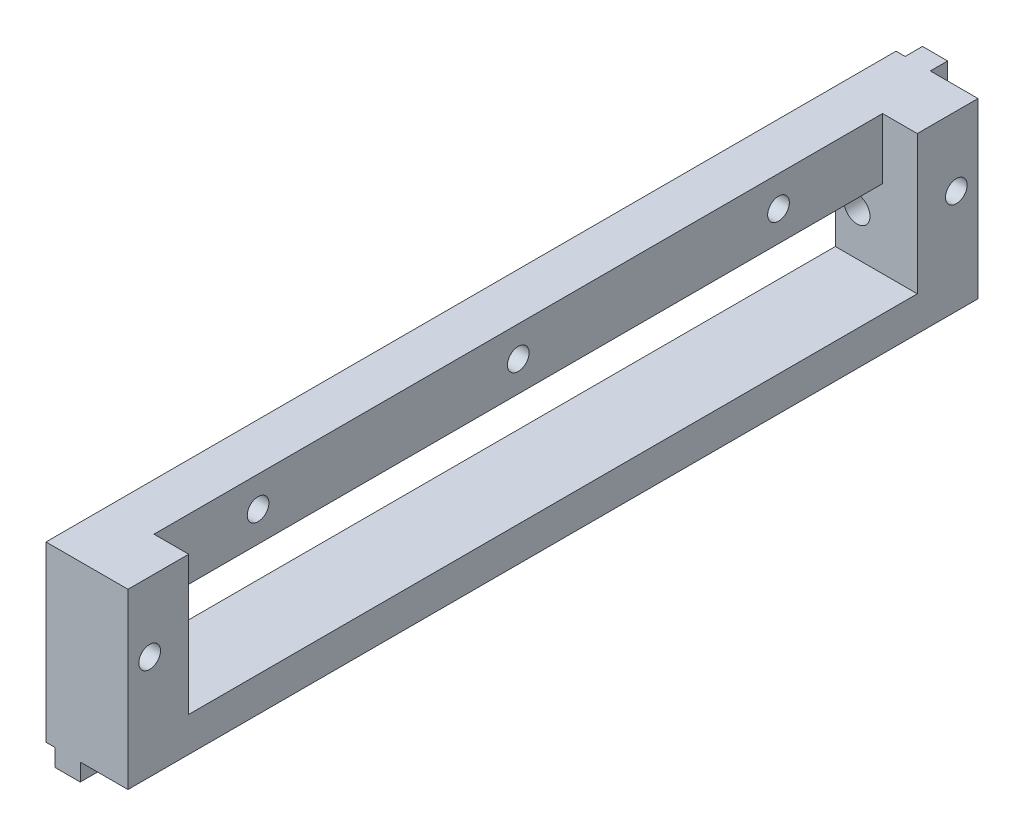
from build123d import *

# Parameters (mm, degrees)
MAIN_DEPTH                       = 49
ESQUISSE2_R                      = 1.25
HOLESFORLCDTOP_DEPTH             = 10.45
SKETCH1_W                        = 84
SKETCH1_H                        = 16
POWERBOARDPINHOLES_DEPTH         = 4
SKETCH2_R                        = 1.25
WINDOWFIXHOLES_DEPTH             = 10.45
SKETCH3_W                        = 2.9
SKETCH3_H                        = 20
MAKERBEAMFIX_DEPTH               = 2
SKETCH4_R                        = 1.5
FIXHOLEFORMAKERBEAM_DEPTH        = 20
SKETCH5_W                        = 84
SKETCH5_H                        = 9
HOLESTOHAVEACCESSTOFIXHOLE_DEPTH = 6.45


with BuildPart() as part:
    # Esquisse1 → Main (new body, symmetric)
    with BuildSketch(Plane.XY):
        Polygon((0, 20), (9.45, 20), (9.45, 0), (3.95, 0), (3.95, -2), (1.05, -2), (1.05, 0), (0, 0), align=None)
    extrude(amount=MAIN_DEPTH, both=True)

    # Esquisse2 → HolesForLCDTop (cut, through all)
    with BuildSketch(Plane(origin=(9.45, 0, 0), x_dir=(0, 0, -1), z_dir=(1, 0, 0))):
        with Locations((46.5, 12)):
            Circle(ESQUISSE2_R)
        with Locations((-46.5, 12)):
            Circle(ESQUISSE2_R)
    extrude(amount=-HOLESFORLCDTOP_DEPTH, mode=Mode.SUBTRACT)

    # Sketch1 → PowerBoardPinHoles (cut)
    with BuildSketch(Plane(origin=(9.45, 0, 0), x_dir=(0, 0, -1), z_dir=(1, 0, 0))):
        with Locations((0, 12)):
            Rectangle(SKETCH1_W, SKETCH1_H)
    extrude(amount=-POWERBOARDPINHOLES_DEPTH, mode=Mode.SUBTRACT)

    # Sketch2 → WindowFixHoles (cut, through all)
    with BuildSketch(Plane.ZY):
        with Locations((0, 16.5)):
            Circle(SKETCH2_R)
        with Locations((-30, 16.5)):
            Circle(SKETCH2_R)
        with Locations((30, 16.5)):
            Circle(SKETCH2_R)
    extrude(amount=-WINDOWFIXHOLES_DEPTH, mode=Mode.SUBTRACT)

    # Sketch3 → MakerBeamFix (add)
    with BuildSketch(Plane(origin=(0, 0, -49), x_dir=(-1, 0, 0), z_dir=(0, 0, -1))):
        with Locations((-2.5, 10)):
            Rectangle(SKETCH3_W, SKETCH3_H)
    extrude(amount=MAKERBEAMFIX_DEPTH)

    # Sketch4 → FixHoleForMakerBeam (cut)
    with BuildSketch(Plane(origin=(0, 0, -51), x_dir=(-1, 0, 0), z_dir=(0, 0, -1))):
        with Locations((-2.5, 9)):
            Circle(SKETCH4_R)
    extrude(amount=-FIXHOLEFORMAKERBEAM_DEPTH, mode=Mode.SUBTRACT)

    # Sketch5 → HolesToHaveAccessToFixHole (cut, through all)
    with BuildSketch(Plane(origin=(5.45, 0, 0), x_dir=(0, 0, -1), z_dir=(1, 0, 0))):
        with Locations((0, 8.5)):
            Rectangle(SKETCH5_W, SKETCH5_H)
    extrude(amount=-HOLESTOHAVEACCESSTOFIXHOLE_DEPTH, mode=Mode.SUBTRACT)


solid = part.part
